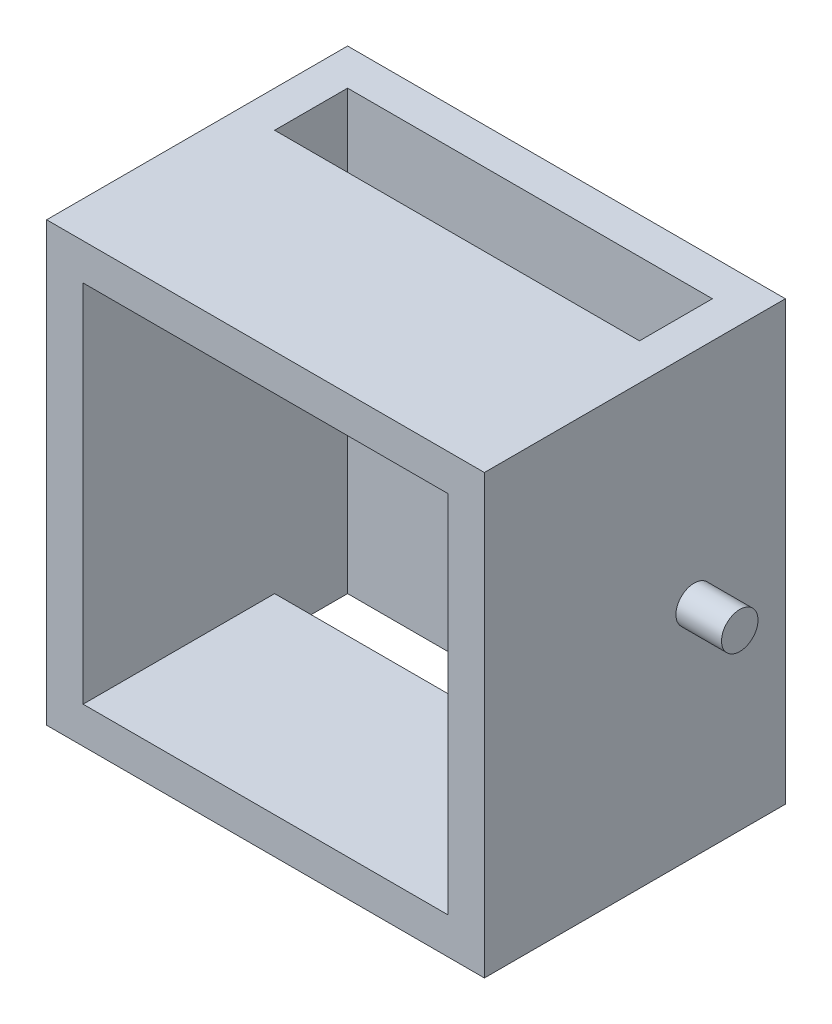
from build123d import *

# Parameters (mm, degrees)
SKETCH1_W           = 48
SKETCH1_H           = 48
BOSS_EXTRUDE1_DEPTH = 33
SHELL1_T            = -4
SKETCH2_W           = 40
SKETCH2_H           = 8
CUT_EXTRUDE1_DEPTH  = 49
SKETCH3_R           = 2
BOSS_EXTRUDE2_DEPTH = 5


with BuildPart() as part:
    # Sketch1 → Boss-Extrude1 (new body)
    with BuildSketch(Plane.XY):
        Rectangle(SKETCH1_W, SKETCH1_H)
    extrude(amount=BOSS_EXTRUDE1_DEPTH)

    # Shell1
    shell1_openings = [part.faces().sort_by_distance(p)[0] for p in [
        (0, 0, 33),
    ]]
    offset(amount=SHELL1_T, openings=shell1_openings, kind=Kind.INTERSECTION)

    # Sketch2 → Cut-Extrude1 (cut, through all)
    with BuildSketch(Plane(origin=(0, 24, 0), x_dir=(1, 0, 0), z_dir=(0, 1, 0))):
        with Locations((0, -8)):
            Rectangle(SKETCH2_W, SKETCH2_H)
    extrude(amount=-CUT_EXTRUDE1_DEPTH, mode=Mode.SUBTRACT)

    # Sketch3 → Boss-Extrude2 (add)
    with BuildSketch(Plane(origin=(24, 0, 0), x_dir=(0, 0, -1), z_dir=(1, 0, 0))):
        with Locations((-10, 0)):
            Circle(SKETCH3_R)
    boss_extrude2 = extrude(amount=BOSS_EXTRUDE2_DEPTH)

    # Mirror1: Boss-Extrude2 across plane
    add(boss_extrude2.mirror(Plane(origin=(0, 0, 0), x_dir=(0, 0, 1), z_dir=(1, 0, 0))))


solid = part.part
